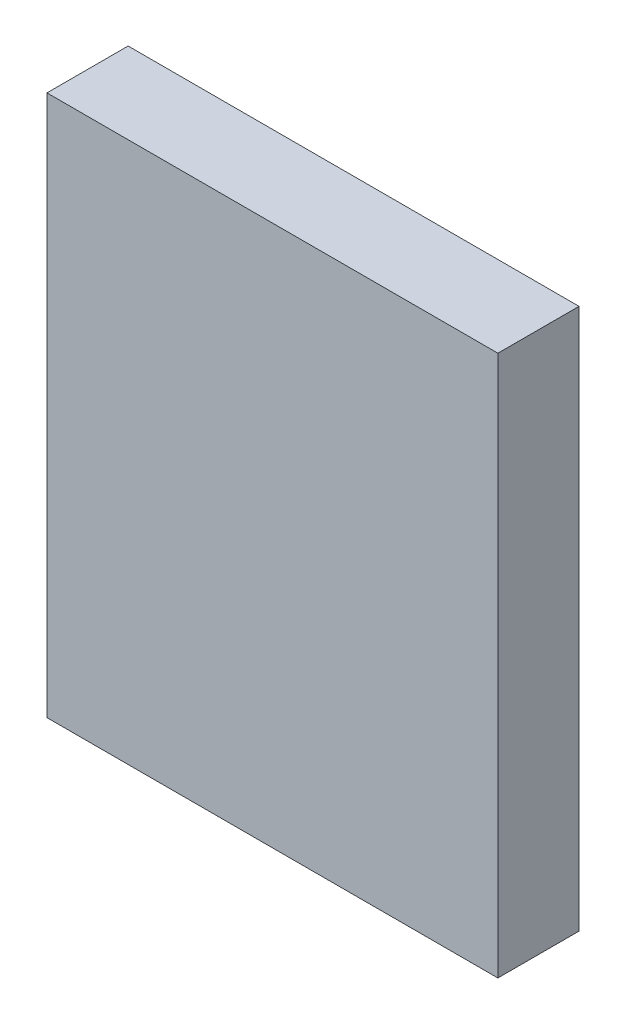
from build123d import *

# Parameters (mm, degrees)
SKETCH1_W           = 100
SKETCH1_H           = 120
BOSS_EXTRUDE1_DEPTH = 18


with BuildPart() as part:
    # Sketch1 → Boss-Extrude1 (new body)
    with BuildSketch(Plane.XY):
        Rectangle(SKETCH1_W, SKETCH1_H)
    extrude(amount=BOSS_EXTRUDE1_DEPTH)


solid = part.part
